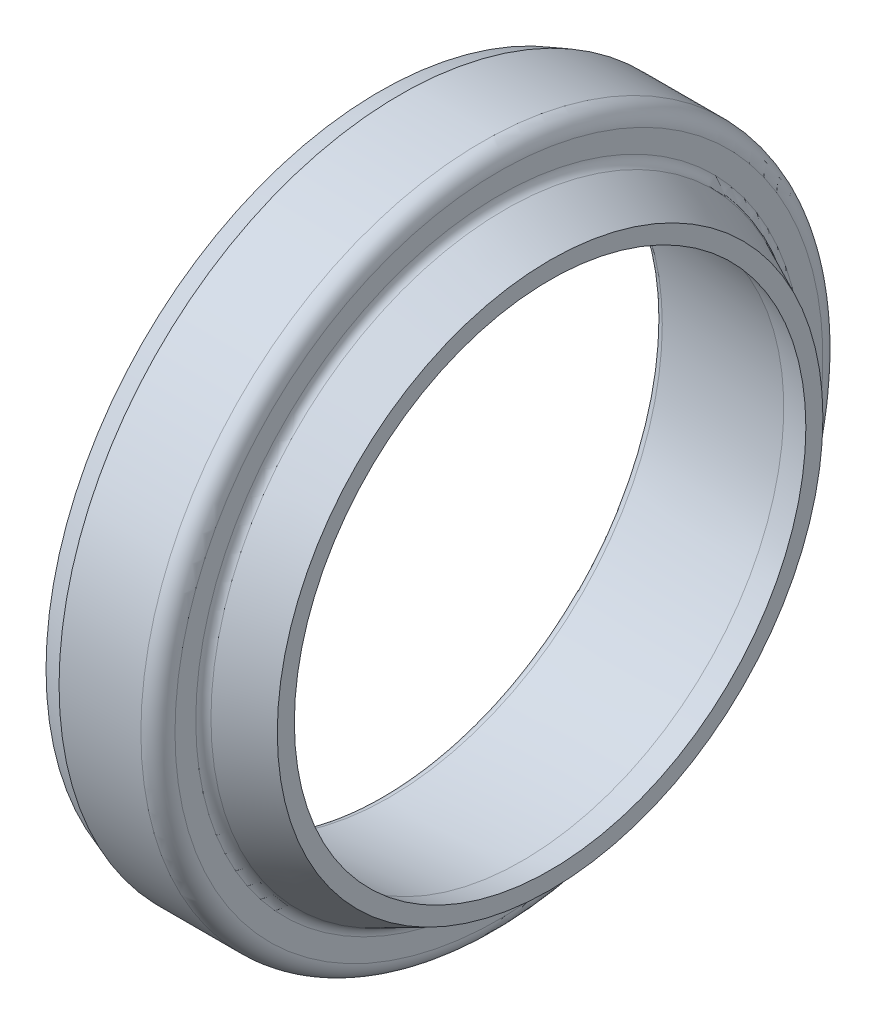
from build123d import *

# Parameters (mm, degrees)
FILLET1_R = 0.6
FILLET2_R = 1


with BuildPart() as part:
    # Sketch1 → Revolve1 (revolve)
    with BuildSketch(Plane.XY):
        Polygon((0, 16.080825938), (0, 19.563235604), (1.2, 19.999999886), (7, 19.999999886), (7, 17.398922974), (10, 16), (10, 15), (8.35338, 15.349999886), align=None)
    revolve(axis=Axis((0, 0, 0), (1, 0, 0)))

    # Fillet1
    fillet1_edges = [part.edges().sort_by_distance(p)[0] for p in [
        (0, -16.080825938, 0),
        (7, -17.398922974, 0),
    ]]
    fillet(fillet1_edges, radius=FILLET1_R)

    # Fillet2
    fillet2_edges = [part.edges().sort_by_distance(p)[0] for p in [
        (7, -19.999999886, 0),
    ]]
    fillet(fillet2_edges, radius=FILLET2_R)


solid = part.part
